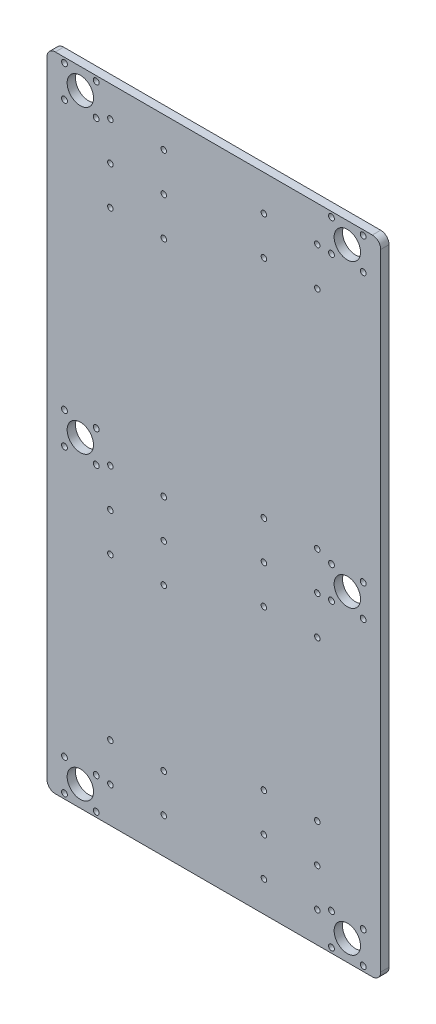
from build123d import *

# Parameters (mm, degrees)
SKETCH_1_W      = 200
SKETCH_1_H      = 385
SKETCH_1_R      = 7.90569415
SKETCH_1_R_2    = 1.65
SKETCH_1_R_3    = 1.75
EXTRUDE_1_DEPTH = 5
FILLET_1_R      = 5


with BuildPart() as part:
    # 草图1 → 凸台-拉伸1 (new body)
    with BuildSketch(Plane.XY):
        Rectangle(SKETCH_1_W, SKETCH_1_H)
        with Locations((-80, 180)):
            Circle(SKETCH_1_R, mode=Mode.SUBTRACT)
        with Locations((-80, 0)):
            Circle(SKETCH_1_R, mode=Mode.SUBTRACT)
        with Locations((-80, -180)):
            Circle(SKETCH_1_R, mode=Mode.SUBTRACT)
        with Locations((80, -180)):
            Circle(SKETCH_1_R, mode=Mode.SUBTRACT)
        with Locations((80, 0)):
            Circle(SKETCH_1_R, mode=Mode.SUBTRACT)
        with Locations((80, 180)):
            Circle(SKETCH_1_R, mode=Mode.SUBTRACT)
        with Locations((-30, 174.165738454)):
            Circle(SKETCH_1_R_2, mode=Mode.SUBTRACT)
        with Locations((-30, 151.165738454)):
            Circle(SKETCH_1_R_2, mode=Mode.SUBTRACT)
        with Locations((-30, 128.165738454)):
            Circle(SKETCH_1_R_2, mode=Mode.SUBTRACT)
        with Locations((-62, 128.165738454)):
            Circle(SKETCH_1_R_2, mode=Mode.SUBTRACT)
        with Locations((-62, 151.165738454)):
            Circle(SKETCH_1_R_2, mode=Mode.SUBTRACT)
        with Locations((-62, 174.165738454)):
            Circle(SKETCH_1_R_2, mode=Mode.SUBTRACT)
        with Locations((-30, -5.702436416)):
            Circle(SKETCH_1_R_2, mode=Mode.SUBTRACT)
        with Locations((-30, -28.702436416)):
            Circle(SKETCH_1_R_2, mode=Mode.SUBTRACT)
        with Locations((-30, -51.702436416)):
            Circle(SKETCH_1_R_2, mode=Mode.SUBTRACT)
        with Locations((-62, -51.702436416)):
            Circle(SKETCH_1_R_2, mode=Mode.SUBTRACT)
        with Locations((-62, -28.702436416)):
            Circle(SKETCH_1_R_2, mode=Mode.SUBTRACT)
        with Locations((-62, -5.702436416)):
            Circle(SKETCH_1_R_2, mode=Mode.SUBTRACT)
        with Locations((30, -128.126766598)):
            Circle(SKETCH_1_R_2, mode=Mode.SUBTRACT)
        with Locations((30, -151.126766598)):
            Circle(SKETCH_1_R_2, mode=Mode.SUBTRACT)
        with Locations((30, -174.126766598)):
            Circle(SKETCH_1_R_2, mode=Mode.SUBTRACT)
        with Locations((62, -174.126766598)):
            Circle(SKETCH_1_R_2, mode=Mode.SUBTRACT)
        with Locations((62, -151.126766598)):
            Circle(SKETCH_1_R_2, mode=Mode.SUBTRACT)
        with Locations((62, -128.126766598)):
            Circle(SKETCH_1_R_2, mode=Mode.SUBTRACT)
        with Locations((-30, -148.12043677)):
            Circle(SKETCH_1_R_2, mode=Mode.SUBTRACT)
        with Locations((-30, -171.12043677)):
            Circle(SKETCH_1_R_2, mode=Mode.SUBTRACT)
        with Locations((-62, -171.12043677)):
            Circle(SKETCH_1_R_2, mode=Mode.SUBTRACT)
        with Locations((-62, -148.12043677)):
            Circle(SKETCH_1_R_2, mode=Mode.SUBTRACT)
        with Locations((30, 13.14999216)):
            Circle(SKETCH_1_R_2, mode=Mode.SUBTRACT)
        with Locations((30, -9.85000784)):
            Circle(SKETCH_1_R_2, mode=Mode.SUBTRACT)
        with Locations((30, -32.85000784)):
            Circle(SKETCH_1_R_2, mode=Mode.SUBTRACT)
        with Locations((62, -32.85000784)):
            Circle(SKETCH_1_R_2, mode=Mode.SUBTRACT)
        with Locations((62, -9.85000784)):
            Circle(SKETCH_1_R_2, mode=Mode.SUBTRACT)
        with Locations((62, 13.14999216)):
            Circle(SKETCH_1_R_2, mode=Mode.SUBTRACT)
        with Locations((30, 171.131672491)):
            Circle(SKETCH_1_R_2, mode=Mode.SUBTRACT)
        with Locations((30, 148.131672491)):
            Circle(SKETCH_1_R_2, mode=Mode.SUBTRACT)
        with Locations((62, 148.131672491)):
            Circle(SKETCH_1_R_2, mode=Mode.SUBTRACT)
        with Locations((62, 171.131672491)):
            Circle(SKETCH_1_R_2, mode=Mode.SUBTRACT)
        with Locations((89.5, -170.5)):
            Circle(SKETCH_1_R_3, mode=Mode.SUBTRACT)
        with Locations((89.5, -189.5)):
            Circle(SKETCH_1_R_3, mode=Mode.SUBTRACT)
        with Locations((70.5, -189.5)):
            Circle(SKETCH_1_R_3, mode=Mode.SUBTRACT)
        with Locations((70.5, -170.5)):
            Circle(SKETCH_1_R_3, mode=Mode.SUBTRACT)
        with Locations((-70.5, -170.5)):
            Circle(SKETCH_1_R_3, mode=Mode.SUBTRACT)
        with Locations((-70.5, -189.5)):
            Circle(SKETCH_1_R_3, mode=Mode.SUBTRACT)
        with Locations((-89.5, -189.5)):
            Circle(SKETCH_1_R_3, mode=Mode.SUBTRACT)
        with Locations((-89.5, -170.5)):
            Circle(SKETCH_1_R_3, mode=Mode.SUBTRACT)
        with Locations((89.5, -9.5)):
            Circle(SKETCH_1_R_3, mode=Mode.SUBTRACT)
        with Locations((70.5, -9.5)):
            Circle(SKETCH_1_R_3, mode=Mode.SUBTRACT)
        with Locations((89.5, 9.5)):
            Circle(SKETCH_1_R_3, mode=Mode.SUBTRACT)
        with Locations((70.5, 9.5)):
            Circle(SKETCH_1_R_3, mode=Mode.SUBTRACT)
        with Locations((89.5, 170.5)):
            Circle(SKETCH_1_R_3, mode=Mode.SUBTRACT)
        with Locations((70.5, 170.5)):
            Circle(SKETCH_1_R_3, mode=Mode.SUBTRACT)
        with Locations((89.5, 189.5)):
            Circle(SKETCH_1_R_3, mode=Mode.SUBTRACT)
        with Locations((70.5, 189.5)):
            Circle(SKETCH_1_R_3, mode=Mode.SUBTRACT)
        with Locations((-70.5, 170.5)):
            Circle(SKETCH_1_R_3, mode=Mode.SUBTRACT)
        with Locations((-89.5, 170.5)):
            Circle(SKETCH_1_R_3, mode=Mode.SUBTRACT)
        with Locations((-70.5, 189.5)):
            Circle(SKETCH_1_R_3, mode=Mode.SUBTRACT)
        with Locations((-89.5, 189.5)):
            Circle(SKETCH_1_R_3, mode=Mode.SUBTRACT)
        with Locations((-89.5, -9.5)):
            Circle(SKETCH_1_R_3, mode=Mode.SUBTRACT)
        with Locations((-70.5, -9.5)):
            Circle(SKETCH_1_R_3, mode=Mode.SUBTRACT)
        with Locations((-70.5, 9.5)):
            Circle(SKETCH_1_R_3, mode=Mode.SUBTRACT)
        with Locations((-89.5, 9.5)):
            Circle(SKETCH_1_R_3, mode=Mode.SUBTRACT)
    extrude(amount=EXTRUDE_1_DEPTH)

    # 圆角1
    fillet_1_edges = [part.edges().sort_by_distance(p)[0] for p in [
        (-100, 192.5, 2.5),
        (100, 192.5, 2.5),
        (100, -192.5, 2.5),
        (-100, -192.5, 2.5),
    ]]
    fillet(fillet_1_edges, radius=FILLET_1_R)


solid = part.part
